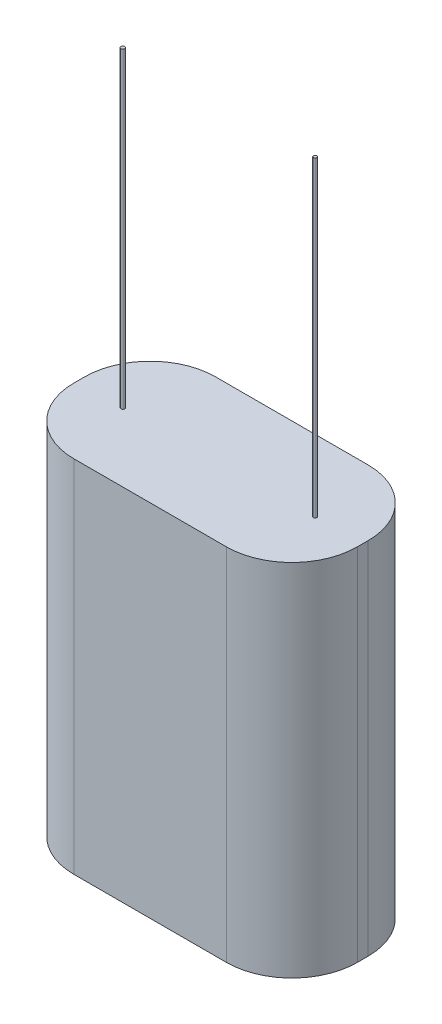
from build123d import *

# Parameters (mm, degrees)
SKETCH1_W           = 16.51
SKETCH1_H           = 20.955
BOSS_EXTRUDE1_DEPTH = 8.255
FILLET1_R           = 3.81
SKETCH2_R           = 0.095779186
SKETCH2_R_2         = 0.11203659
BOSS_EXTRUDE2_DEPTH = 18.161


with BuildPart() as part:
    # Sketch1 → Boss-Extrude1 (new body)
    with BuildSketch(Plane.XY):
        with Locations((-5.510011418, -21.415196798)):
            Rectangle(SKETCH1_W, SKETCH1_H)
    extrude(amount=BOSS_EXTRUDE1_DEPTH)

    # Fillet1
    fillet1_edges = [part.edges().sort_by_distance(p)[0] for p in [
        (-13.765011418, -21.415196798, 8.255),
        (2.744988582, -21.415196798, 8.255),
        (-13.765011418, -21.415196798, 0),
        (2.744988582, -21.415196798, 0),
    ]]
    fillet(fillet1_edges, radius=FILLET1_R)

    # Sketch2 → Boss-Extrude2 (add)
    with BuildSketch(Plane(origin=(0, -10.937696798, 0), x_dir=(1, 0, 0), z_dir=(0, 1, 0))):
        with Locations(Location((0, -4.160603471, 0), (0, 0, 90))):  # turned: the seam where the file's is
            Circle(SKETCH2_R)
        with Locations(Location((-11.093960289, -4.256382657, 0), (0, 0, 90))):  # turned: the seam where the file's is
            Circle(SKETCH2_R_2)
    extrude(amount=BOSS_EXTRUDE2_DEPTH)


solid = part.part
